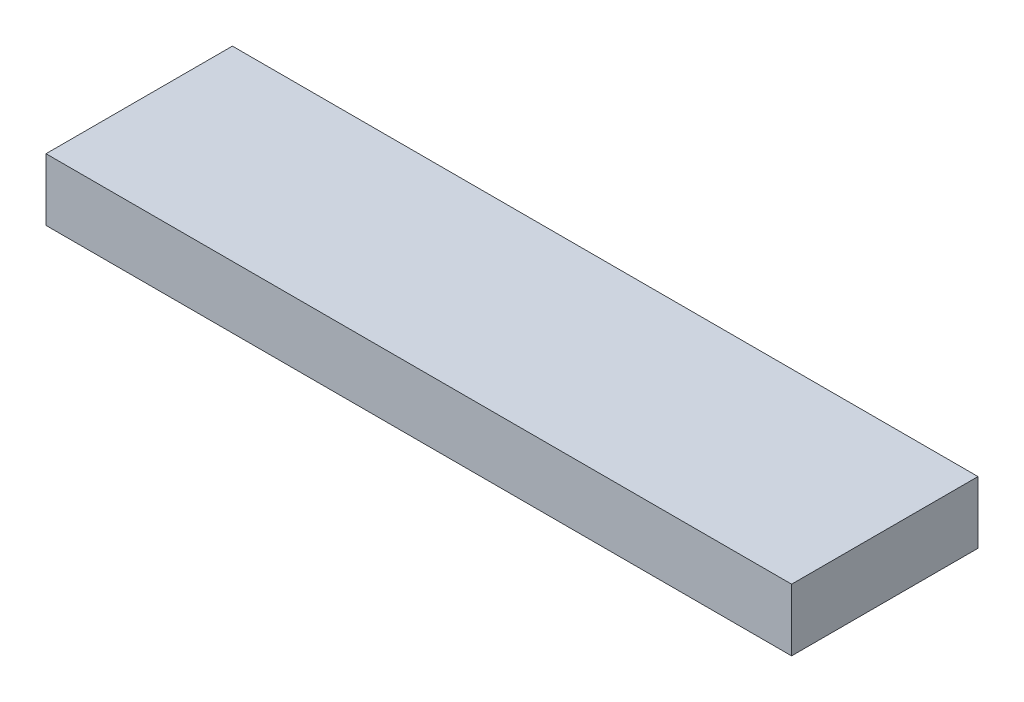
from build123d import *

# Parameters (mm, degrees)
SKETCH1_W           = 76.2
SKETCH1_H           = 19.05
BOSS_EXTRUDE1_DEPTH = 6.35


with BuildPart() as part:
    # Sketch1 → Boss-Extrude1 (new body)
    with BuildSketch(Plane(origin=(0, 0, 0), x_dir=(1, 0, 0), z_dir=(0, 1, 0))):
        Rectangle(SKETCH1_W, SKETCH1_H)
    extrude(amount=BOSS_EXTRUDE1_DEPTH)


solid = part.part
